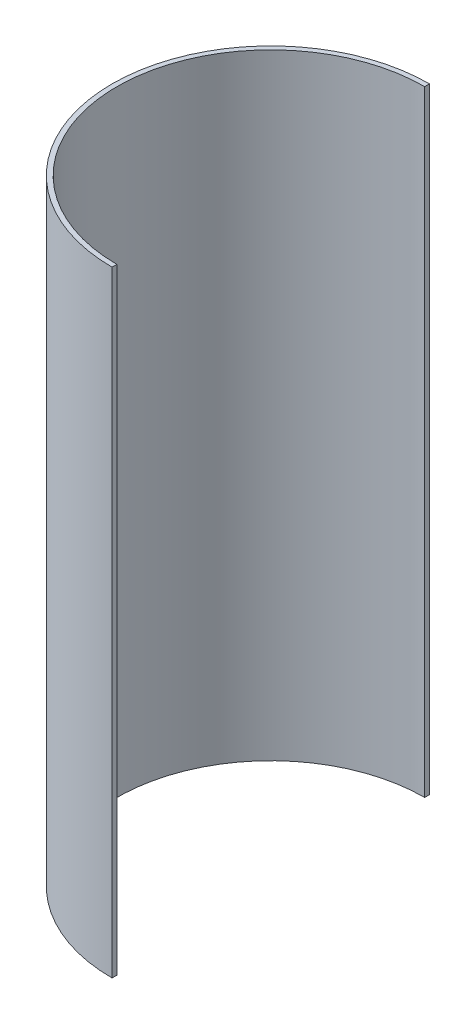
from build123d import *

# Parameters (mm, degrees)
BOSS_EXTRUDE1_DEPTH = 406.4


with BuildPart() as part:
    # Sketch1 → Boss-Extrude1 (new body)
    with BuildSketch(Plane(origin=(0, 0, 0), x_dir=(1, 0, 0), z_dir=(0, 1, 0))):
        with BuildLine():
            Line((0, 101.6), (0, 104.775))
            ThreePointArc((0, 104.775), (-104.775, 0), (0, -104.775))
            Line((0, -104.775), (0, -101.6))
            ThreePointArc((0, -101.6), (-101.6, 0), (0, 101.6))
        make_face()
    extrude(amount=BOSS_EXTRUDE1_DEPTH)


solid = part.part
